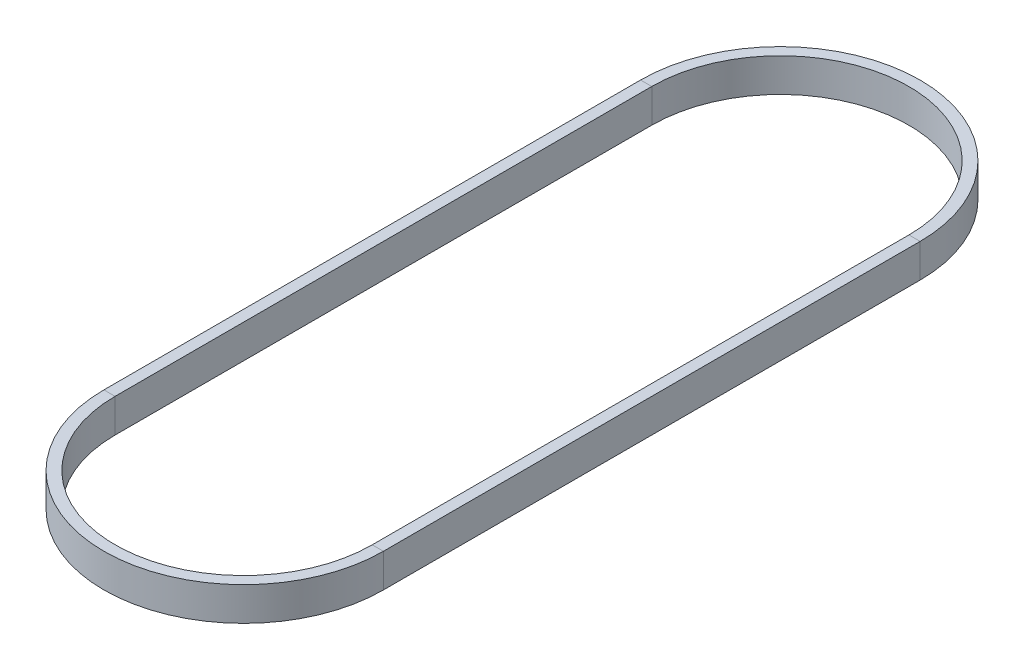
from build123d import *

# Parameters (mm, degrees)
SKETCH2_W = 2
SKETCH2_H = 6


with BuildPart() as part:
    # Sweep1: sweep along a path in Sketch1
    with BuildLine(Plane(origin=(0, 0, 0), x_dir=(1, 0, 0), z_dir=(0, 1, 0))) as sweep1_path:
        Line((787.522377583, -234.011074688), (787.522377583, -330.011074688))
        ThreePointArc((787.522377583, -330.011074688), (763.522377583, -354.011074688), (739.522377583, -330.011074688))
        Line((739.522377583, -330.011074688), (739.522377583, -234.011074688))
        ThreePointArc((739.522377583, -234.011074688), (763.522377583, -210.011074688), (787.522377583, -234.011074688))
    # Sketch2 → Sweep1 (sweep)
    with BuildSketch(Plane(origin=(739.522377583, 0, 234.011074688), x_dir=(-1, 0, 0), z_dir=(0, 0, -1))):
        Rectangle(SKETCH2_W, SKETCH2_H)
    sweep(path=sweep1_path.line)


solid = part.part
